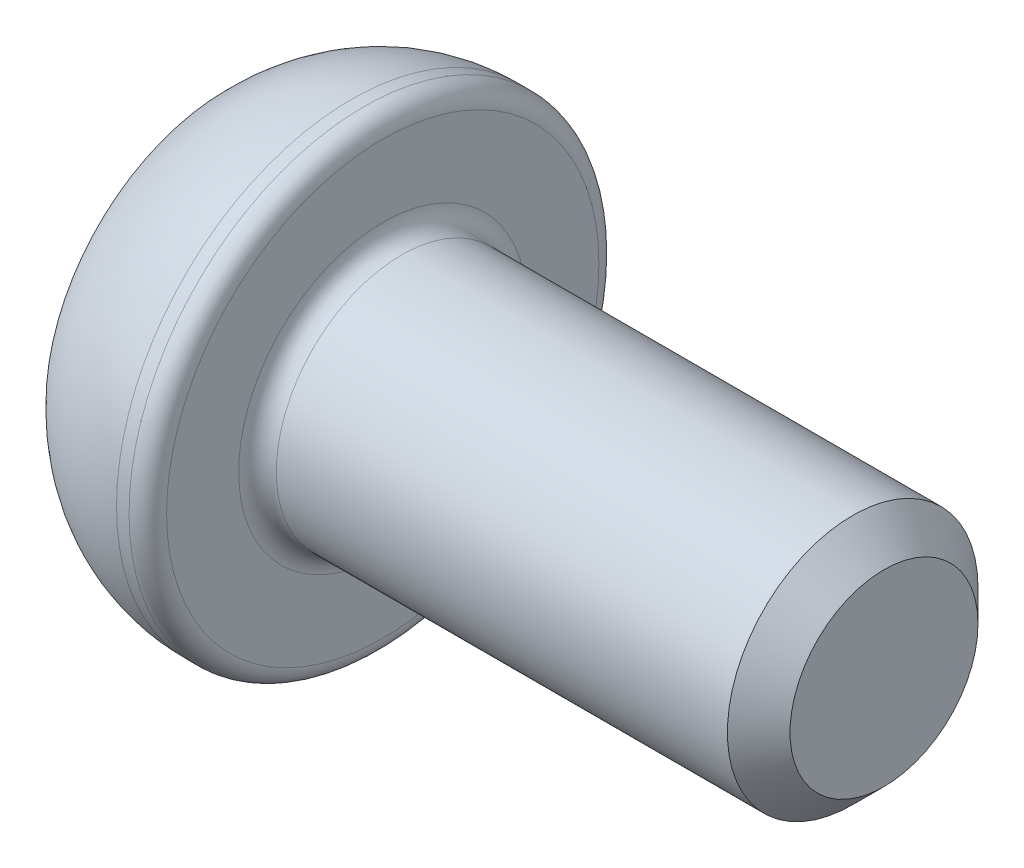
from build123d import *

# Parameters (mm, degrees)
CUT_EXTRUDE_1_DEPTH = 1.5
FILLET_1_R          = 0.3
CHAMFER_1_SIZE      = 0.5


with BuildPart() as part:
    # Эскиз1 → Повернуть1 (revolve)
    with BuildSketch(Plane.XY, mode=Mode.PRIVATE) as revolve_1_sk:
        with BuildLine():
            Line((0, 0), (0, 2.875))
            ThreePointArc((0, 2.875), (0.908484425, 3.521678457), (2, 3.75))
            Line((2, 3.75), (2.5, 3.75))
            Line((2.5, 3.75), (2.5, 2))
            Line((2.5, 2), (10.5, 2))
            Line((10.5, 2), (10.5, 0))
            Line((10.5, 0), (0, 0))
        make_face()
    revolve(revolve_1_sk.sketch.rotate(Axis((10.5, 0, 0), (-1, 0, 0)), 90), axis=Axis((10.5, 0, 0), (-1, 0, 0)))  # turned: the seam where the file's is

    # Эскиз2 → Вырез-Вытянуть1 (cut)
    with BuildSketch(Plane.ZY):
        Polygon((0.721687836, 1.25), (-0.721687836, 1.25), (-1.443375673, 0), (-0.721687836, -1.25), (0.721687836, -1.25), (1.443375673, 0), align=None)
    extrude(amount=-CUT_EXTRUDE_1_DEPTH, mode=Mode.SUBTRACT)

    # Скругление1
    fillet_1_edges = [part.edges().sort_by_distance(p)[0] for p in [
        (2.5, 0, 2),
        (2.5, 0, 3.75),
    ]]
    fillet(fillet_1_edges, radius=FILLET_1_R)

    # Фаска1
    chamfer_1_edges = [part.edges().sort_by_distance(p)[0] for p in [
        (10.5, 0, 2),
    ]]
    chamfer(chamfer_1_edges, length=CHAMFER_1_SIZE)


solid = part.part
